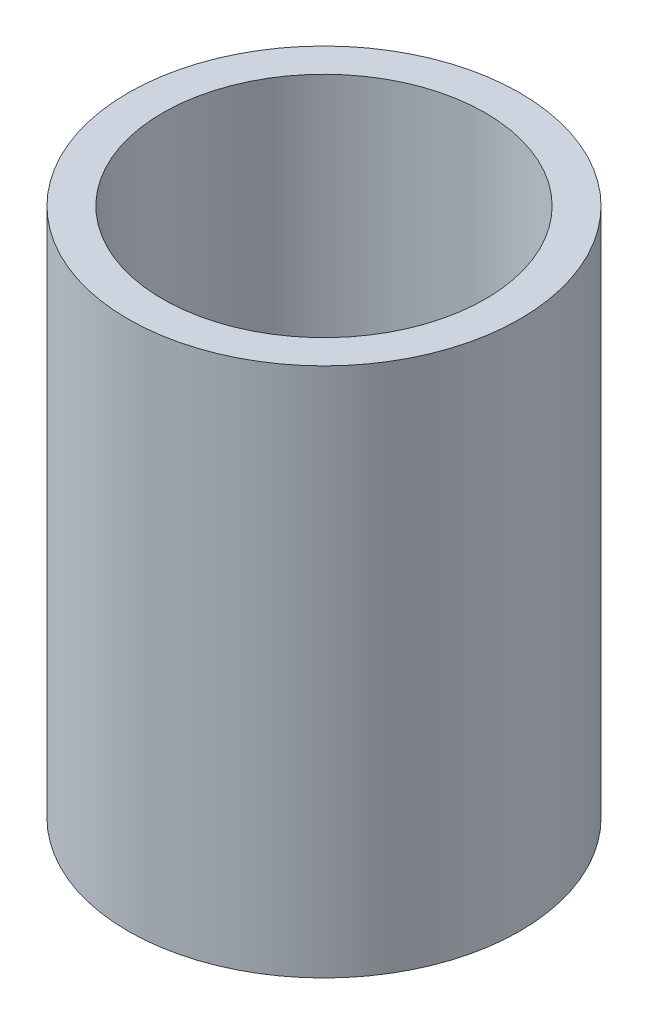
from build123d import *


with BuildPart() as part:
    # Szkic1 → Obrót2 (revolve)
    with BuildSketch(Plane.XY):
        Polygon((8.5, 0), (8.5, 23), (7, 23), (7, 12), (5.196152423, 12), (0, 9), (0, 4), (7, 4), (7, 0), align=None)
    revolve(axis=Axis((0, 0, 0), (0, 1, 0)))


solid = part.part
